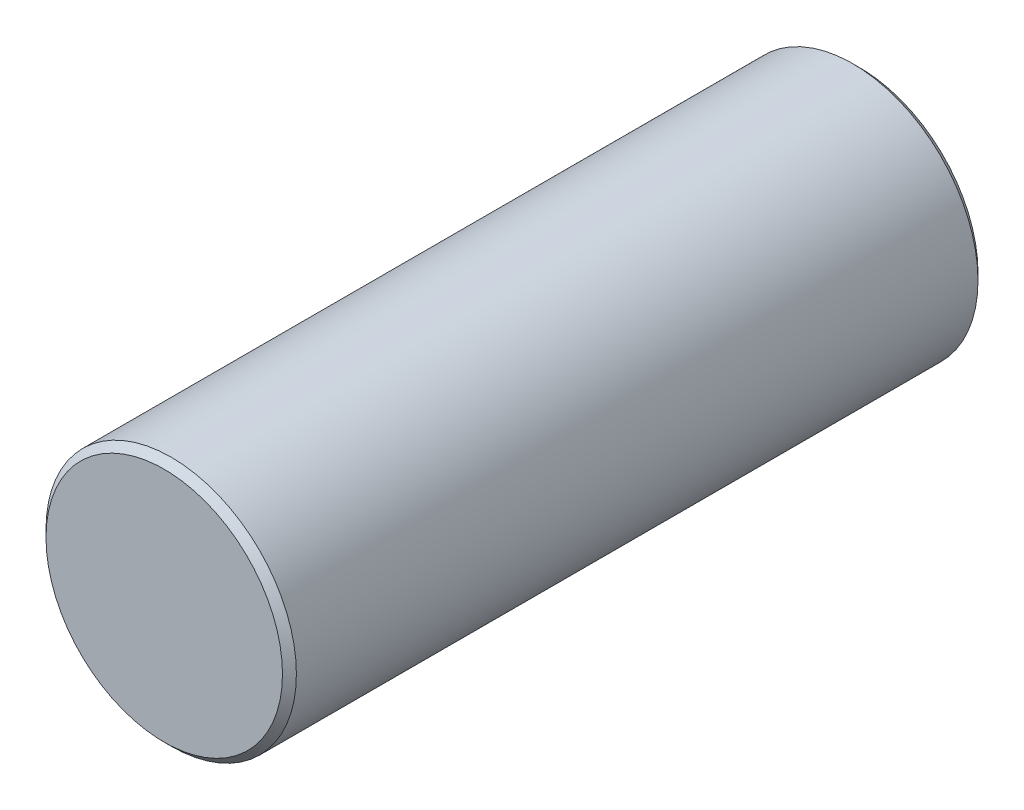
from build123d import *

# Parameters (mm, degrees)
CHAMFER1_SIZE = 0.5


with BuildPart() as part:
    # Sketch1 → Revolve1 (revolve)
    with BuildSketch(Plane(origin=(0, 0, 0), x_dir=(0, 0, -1), z_dir=(1, 0, 0))):
        Polygon((0, 0), (35, 0), (38, 3), (50, 3), (50, 9), (0, 9), align=None)
    revolve(axis=Axis((0, 0, 494.673459935), (0, 0, -1)))

    # Chamfer1
    chamfer1_edges = [part.edges().sort_by_distance(p)[0] for p in [
        (0, -9, 0),
        (0, -9, -50),
        (0, -3, -50),
    ]]
    chamfer(chamfer1_edges, length=CHAMFER1_SIZE)


solid = part.part
